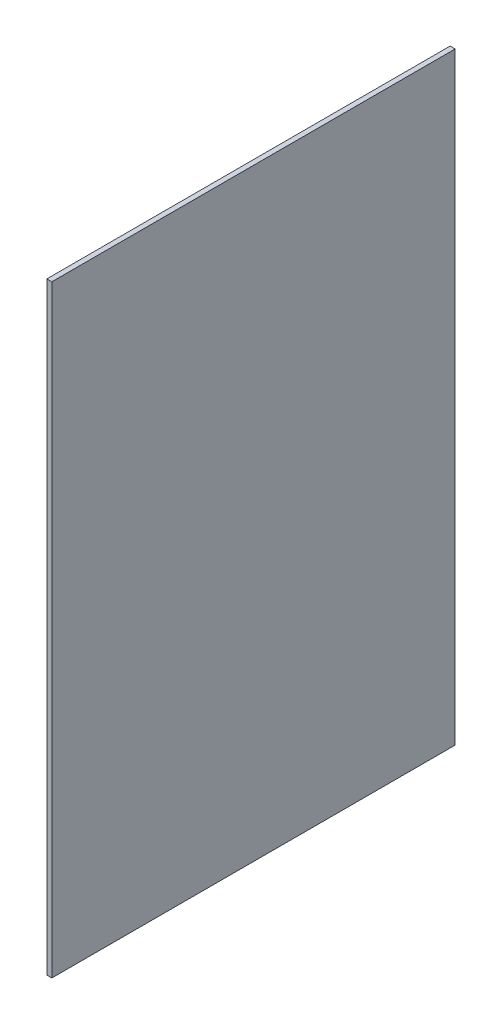
from build123d import *

# Parameters (mm, degrees)
SKETCH1_W           = 1.39446
SKETCH1_H           = 167.8
BOSS_EXTRUDE1_DEPTH = 112.268


with BuildPart() as part:
    # Sketch1 → Boss-Extrude1 (new body)
    with BuildSketch(Plane.XY):
        with Locations((178.49723, -83.9)):
            Rectangle(SKETCH1_W, SKETCH1_H)
    extrude(amount=BOSS_EXTRUDE1_DEPTH)


solid = part.part
